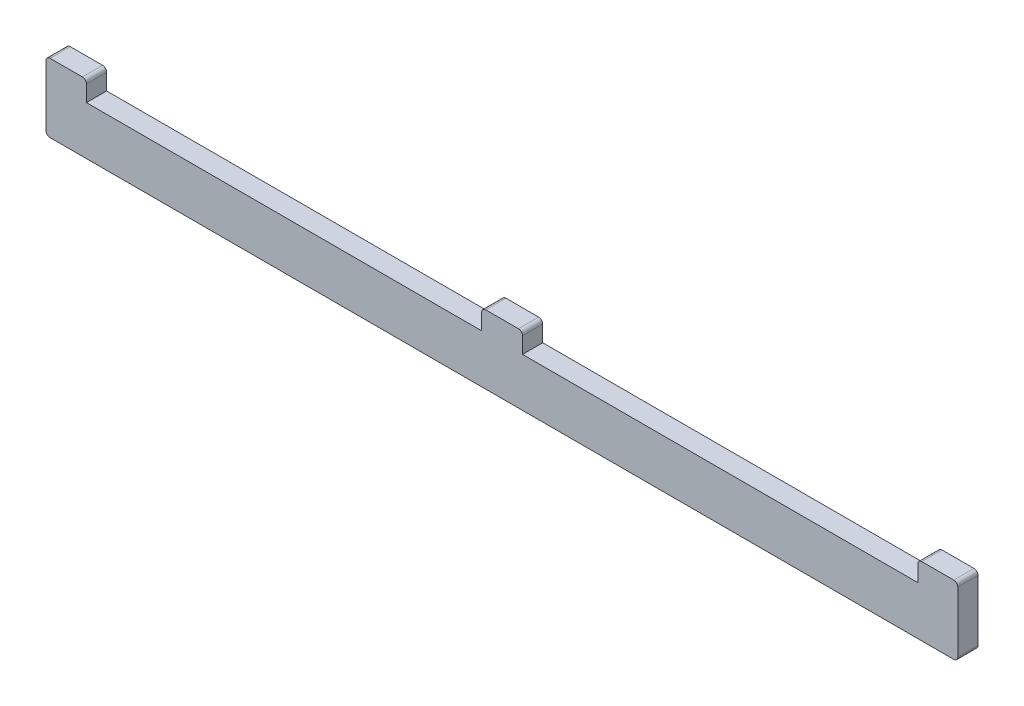
from build123d import *

# Parameters (mm, degrees)
BOSS_EXTRUDE1_DEPTH = 5


with BuildPart() as part:
    # Sketch1 → Boss-Extrude1 (new body)
    with BuildSketch(Plane.XY):
        with BuildLine():
            Line((117.9, 12), (215.7, 12))
            Line((215.7, 12), (215.7, 16))
            ThreePointArc((215.7, 16), (215.992893219, 16.707106781), (216.7, 17))
            Line((216.7, 17), (224.6, 17))
            ThreePointArc((224.6, 17), (225.307106781, 16.707106781), (225.6, 16))
            Line((225.6, 16), (225.6, 1))
            ThreePointArc((225.6, 1), (225.307106781, 0.292893219), (224.6, 0))
            Line((224.6, 0), (1, 0))
            ThreePointArc((1, 0), (0.292893219, 0.292893219), (0, 1))
            Line((0, 1), (0, 16))
            ThreePointArc((0, 16), (0.292893219, 16.707106781), (1, 17))
            Line((1, 17), (9, 17))
            ThreePointArc((9, 17), (9.707106781, 16.707106781), (10, 16))
            Line((10, 16), (10, 12))
            Line((10, 12), (107.8, 12))
            Line((107.8, 12), (107.8, 16))
            ThreePointArc((107.8, 16), (108.092893219, 16.707106781), (108.8, 17))
            Line((108.8, 17), (116.9, 17))
            ThreePointArc((116.9, 17), (117.607106781, 16.707106781), (117.9, 16))
            Line((117.9, 16), (117.9, 12))
        make_face()
    extrude(amount=BOSS_EXTRUDE1_DEPTH)


solid = part.part
